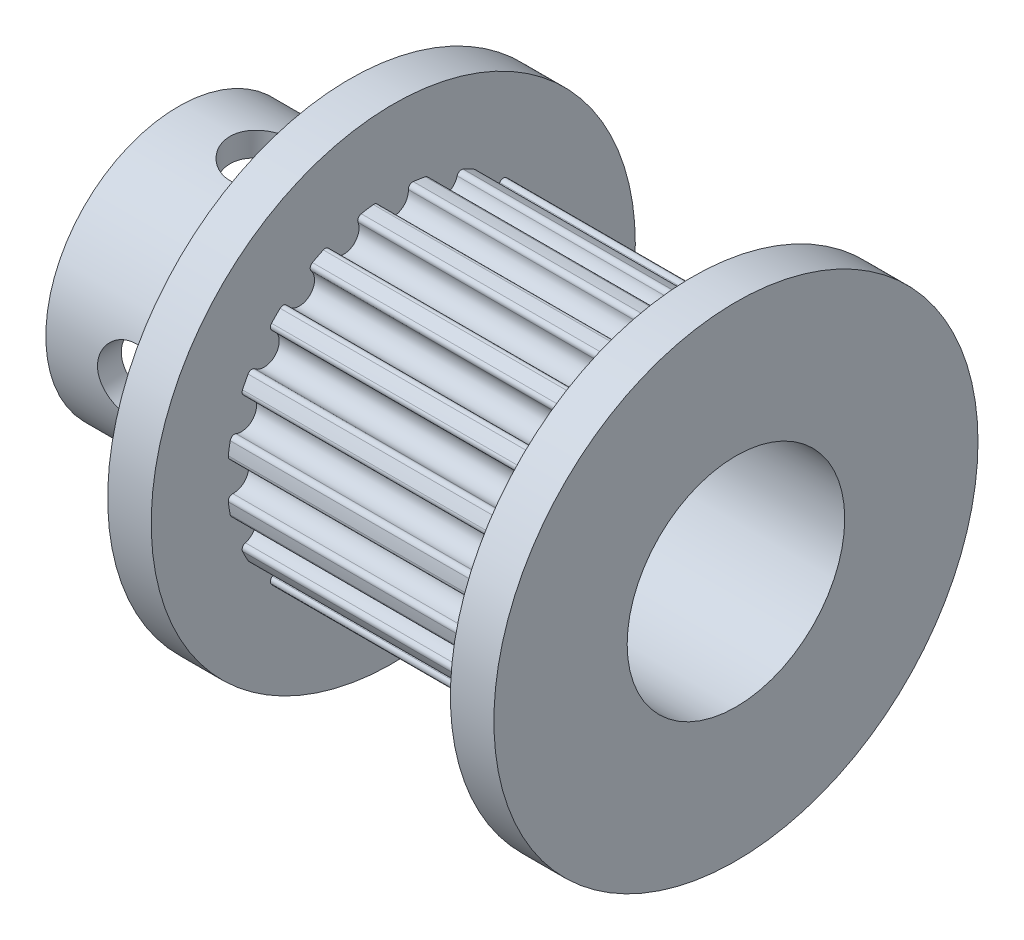
from build123d import *

# Parameters (mm, degrees)
CROQUIS5_R            = 0.555
CORTAR_EXTRUIR1_DEPTH = 11
REDONDEO1_R           = 0.16
SKETCH2_W             = 1.25
SKETCH2_H             = 8.9
SKETCH4_W             = 1.25
SKETCH4_H             = 8.9


with BuildPart() as part:
    # Sketch1 → Revolve1 (revolve)
    with BuildSketch(Plane.XY):
        Polygon((0, 4), (0, 4.875), (6.3, 4.875), (6.3, 8.9), (7.9, 8.9), (7.9, 6.11), (18.9, 6.11), (18.9, 8.9), (20.5, 8.9), (20.5, 4), align=None)
    revolve(axis=Axis((0, 0, 0), (-1, 0, 0)))

    # Croquis5 → Cortar-Extruir1 (cut)
    with BuildSketch(Plane.ZY.offset(-18.9)):
        with Locations((0, 5.87)):
            Circle(CROQUIS5_R)
        with Locations((1.813929757, 5.582701751)):
            Circle(CROQUIS5_R)
        with Locations((3.450299431, 4.748929757)):
            Circle(CROQUIS5_R)
        with Locations((4.748929757, 3.450299431)):
            Circle(CROQUIS5_R)
        with Locations((5.582701751, 1.813929757)):
            Circle(CROQUIS5_R)
        with Locations((5.87, 0)):
            Circle(CROQUIS5_R)
        with Locations((5.582701751, -1.813929757)):
            Circle(CROQUIS5_R)
        with Locations((4.748929757, -3.450299431)):
            Circle(CROQUIS5_R)
        with Locations((3.450299431, -4.748929757)):
            Circle(CROQUIS5_R)
        with Locations((1.813929757, -5.582701751)):
            Circle(CROQUIS5_R)
        with Locations((0, -5.87)):
            Circle(CROQUIS5_R)
        with Locations((-1.813929757, -5.582701751)):
            Circle(CROQUIS5_R)
        with Locations((-3.450299431, -4.748929757)):
            Circle(CROQUIS5_R)
        with Locations((-4.748929757, -3.450299431)):
            Circle(CROQUIS5_R)
        with Locations((-5.582701751, -1.813929757)):
            Circle(CROQUIS5_R)
        with Locations((-5.87, 0)):
            Circle(CROQUIS5_R)
        with Locations((-5.582701751, 1.813929757)):
            Circle(CROQUIS5_R)
        with Locations((-4.748929757, 3.450299431)):
            Circle(CROQUIS5_R)
        with Locations((-3.450299431, 4.748929757)):
            Circle(CROQUIS5_R)
        with Locations((-1.813929757, 5.582701751)):
            Circle(CROQUIS5_R)
    extrude(amount=CORTAR_EXTRUIR1_DEPTH, mode=Mode.SUBTRACT)

    # Redondeo1
    redondeo1_edges = [part.edges().sort_by_distance(p)[0] for p in [
        (13.4, -5.94830004, 1.396361929),
        (13.4, -5.633036769, 2.366642509),
        (13.4, -6.08866908, -0.510106688),
        (13.4, -6.08866908, 0.510106688),
        (13.4, -5.633036769, -2.366642509),
        (13.4, -5.94830004, -1.396361929),
        (13.4, -4.62600357, -3.991514871),
        (13.4, -5.225669947, -3.166144912),
        (13.4, -3.166144912, -5.225669947),
        (13.4, -3.991514871, -4.62600357),
        (13.4, -1.396361929, -5.94830004),
        (13.4, -2.366642509, -5.633036769),
        (13.4, 0.510106688, -6.08866908),
        (13.4, -0.510106688, -6.08866908),
        (13.4, 2.366642509, -5.633036769),
        (13.4, 1.396361929, -5.94830004),
        (13.4, 3.991514871, -4.62600357),
        (13.4, 3.166144912, -5.225669947),
        (13.4, 5.225669947, -3.166144912),
        (13.4, 4.62600357, -3.991514871),
        (13.4, 5.94830004, -1.396361929),
        (13.4, 5.633036769, -2.366642509),
        (13.4, 6.08866908, 0.510106688),
        (13.4, 6.08866908, -0.510106688),
        (13.4, 5.633036769, 2.366642509),
        (13.4, 5.94830004, 1.396361929),
        (13.4, 4.62600357, 3.991514871),
        (13.4, 5.225669947, 3.166144912),
        (13.4, 3.166144912, 5.225669947),
        (13.4, 3.991514871, 4.62600357),
        (13.4, 1.396361929, 5.94830004),
        (13.4, 2.366642509, 5.633036769),
        (13.4, -0.510106688, 6.08866908),
        (13.4, 0.510106688, 6.08866908),
        (13.4, -2.366642509, 5.633036769),
        (13.4, -1.396361929, 5.94830004),
        (13.4, -3.991514871, 4.62600357),
        (13.4, -3.166144912, 5.225669947),
        (13.4, -5.225669947, 3.166144912),
        (13.4, -4.62600357, 3.991514871),
    ]]
    fillet(redondeo1_edges, radius=REDONDEO1_R)

    # Sketch2 → M3x0.5 Tapped Hole1 (revolve, cut)
    with BuildSketch(Plane(origin=(3.15, 0, 0), x_dir=(0, 0, -1), z_dir=(1, 0, 0))):
        with Locations((0.625, 4.45)):
            Rectangle(SKETCH2_W, SKETCH2_H)
    revolve(axis=Axis((3.15, -6.35, 0), (0, 1, 0)), mode=Mode.SUBTRACT)

    # Sketch4 → M3x0.5 Tapped Hole2 (revolve, cut)
    with BuildSketch(Plane.YZ.offset(3.15)):
        with Locations((0.625, 4.45)):
            Rectangle(SKETCH4_W, SKETCH4_H)
    revolve(axis=Axis((3.15, 0, -6.35), (0, 0, 1)), mode=Mode.SUBTRACT)


solid = part.part
